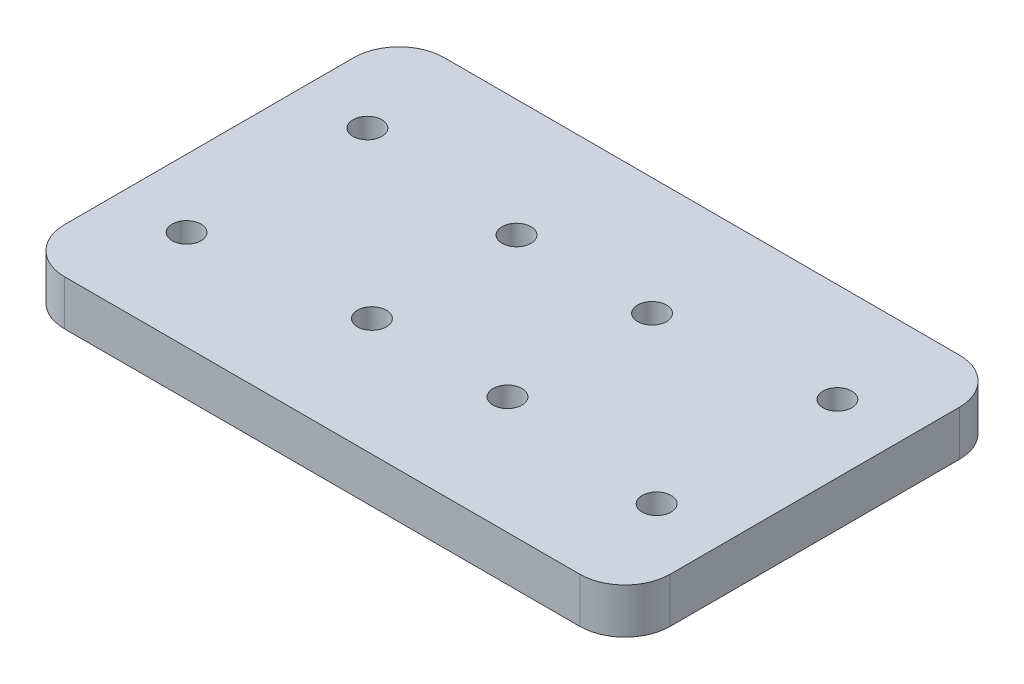
from build123d import *

# Parameters (mm, degrees)
SKETCH1_W           = 67
SKETCH1_H           = 42
SKETCH1_R           = 1.6
BOSS_EXTRUDE1_DEPTH = 5
SKETCH2_R           = 1.6
CUT_EXTRUDE1_DEPTH  = 6
FILLET1_R           = 5


with BuildPart() as part:
    # Sketch1 → Boss-Extrude1 (new body)
    with BuildSketch(Plane(origin=(0, 0, 0), x_dir=(1, 0, 0), z_dir=(0, 1, 0))):
        with Locations((33.5, 21)):
            Rectangle(SKETCH1_W, SKETCH1_H)
        with Locations((7.5, 31)):
            Circle(SKETCH1_R, mode=Mode.SUBTRACT)
        with Locations((7.5, 11)):
            Circle(SKETCH1_R, mode=Mode.SUBTRACT)
        with Locations((59.5, 11)):
            Circle(SKETCH1_R, mode=Mode.SUBTRACT)
        with Locations((59.5, 31)):
            Circle(SKETCH1_R, mode=Mode.SUBTRACT)
    extrude(amount=BOSS_EXTRUDE1_DEPTH)

    # Sketch2 → Cut-Extrude1 (cut, through all)
    with BuildSketch(Plane(origin=(0, 5, 0), x_dir=(1, 0, 0), z_dir=(0, 1, 0))):
        with Locations((41, 29)):
            Circle(SKETCH2_R)
        with Locations((41, 13)):
            Circle(SKETCH2_R)
        with Locations((26, 13)):
            Circle(SKETCH2_R)
        with Locations((26, 29)):
            Circle(SKETCH2_R)
    extrude(amount=-CUT_EXTRUDE1_DEPTH, mode=Mode.SUBTRACT)

    # Fillet1
    fillet1_edges = [part.edges().sort_by_distance(p)[0] for p in [
        (0, 2.5, -42),
        (67, 2.5, -42),
        (67, 2.5, 0),
        (0, 2.5, 0),
    ]]
    fillet(fillet1_edges, radius=FILLET1_R)


solid = part.part
